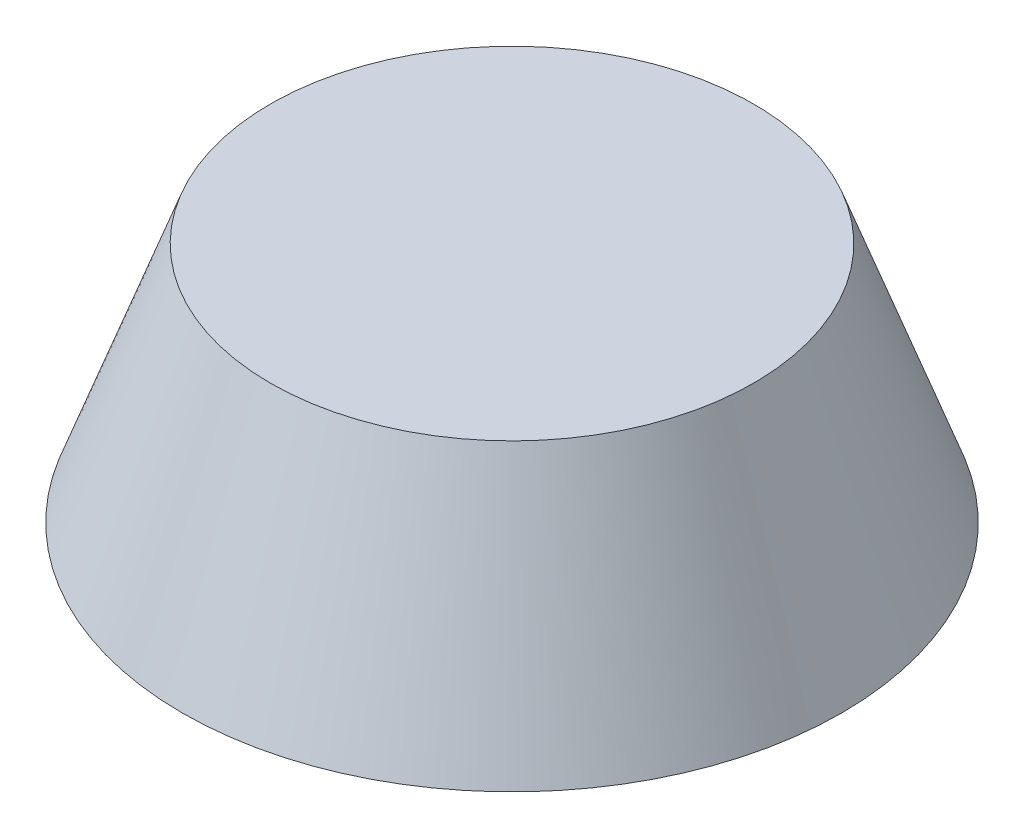
from build123d import *

# Parameters (mm, degrees)
SKETCH1_R           = 3
BOSS_EXTRUDE1_DEPTH = 3
DRAFT2_ANGLE        = 1
DRAFT3_ANGLE        = 20


with BuildPart() as part:
    # Sketch1 → Boss-Extrude1 (new body)
    with BuildSketch(Plane(origin=(0, 0, 0), x_dir=(1, 0, 0), z_dir=(0, 1, 0))):
        Circle(SKETCH1_R)
    extrude(amount=BOSS_EXTRUDE1_DEPTH)

    # Draft2
    draft2_faces = [part.faces().sort_by_distance(p)[0] for p in [
        (-3, 1.5, 0),
    ]]
    draft(draft2_faces, Plane.ZX.offset(3), DRAFT2_ANGLE)

    # Draft3
    draft3_faces = [part.faces().sort_by_distance(p)[0] for p in [
        (-3.026182597, 1.5, 0),
    ]]
    draft(draft3_faces, Plane.ZX.offset(3), DRAFT3_ANGLE)


solid = part.part
